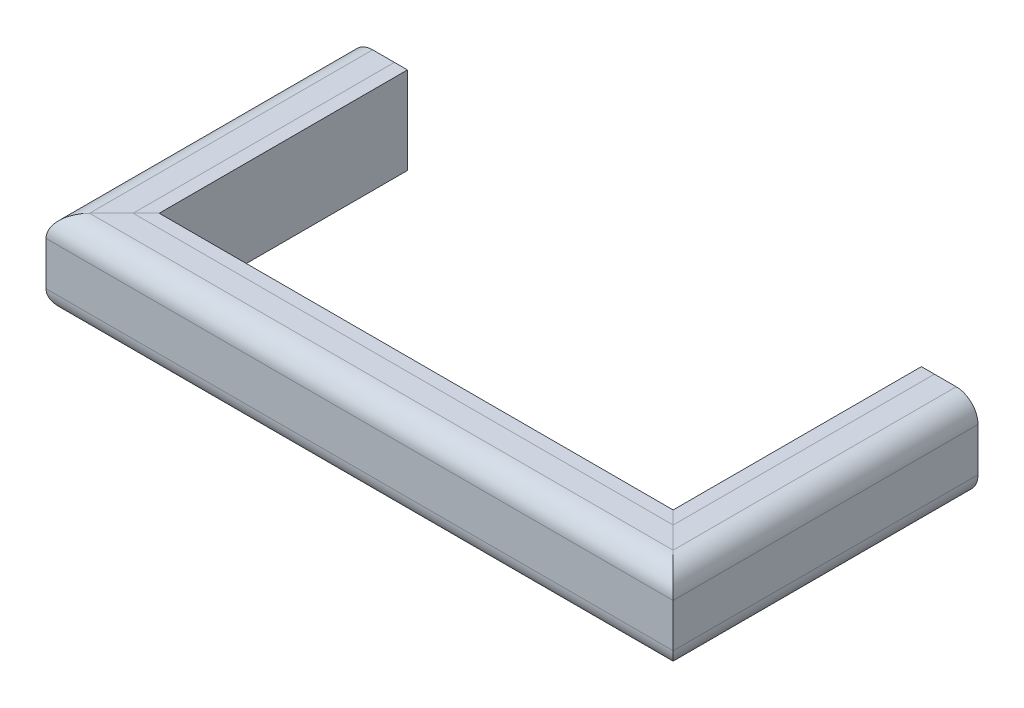
from build123d import *


with BuildPart() as part:
    # Sweep1: sweep along a path in Sketch2
    with BuildLine(Plane(origin=(0, 0, 0), x_dir=(1, 0, 0), z_dir=(0, 1, 0))) as sweep1_path:
        Line((-374.65, 0), (-374.65, -361.95))
        Line((-374.65, -361.95), (374.65, -361.95))
        Line((374.65, -361.95), (374.65, 0))
    # Sketch1 → Sweep1 (sweep)
    with BuildSketch(Plane.XY):
        with BuildLine():
            Line((-393.7, 127), (-425.45, 127))
            ThreePointArc((-425.45, 127), (-447.900640303, 117.700640303), (-457.2, 95.25))
            Line((-457.2, 95.25), (-457.2, 31.75))
            ThreePointArc((-457.2, 31.75), (-447.900640303, 9.299359697), (-425.45, 0))
            Line((-425.45, 0), (-393.7, 0))
            Line((-393.7, 0), (-374.65, 0))
            Line((-374.65, 0), (-374.65, 127))
            Line((-374.65, 127), (-393.7, 127))
        make_face()
    sweep(path=sweep1_path.line, transition=Transition.RIGHT)


solid = part.part
